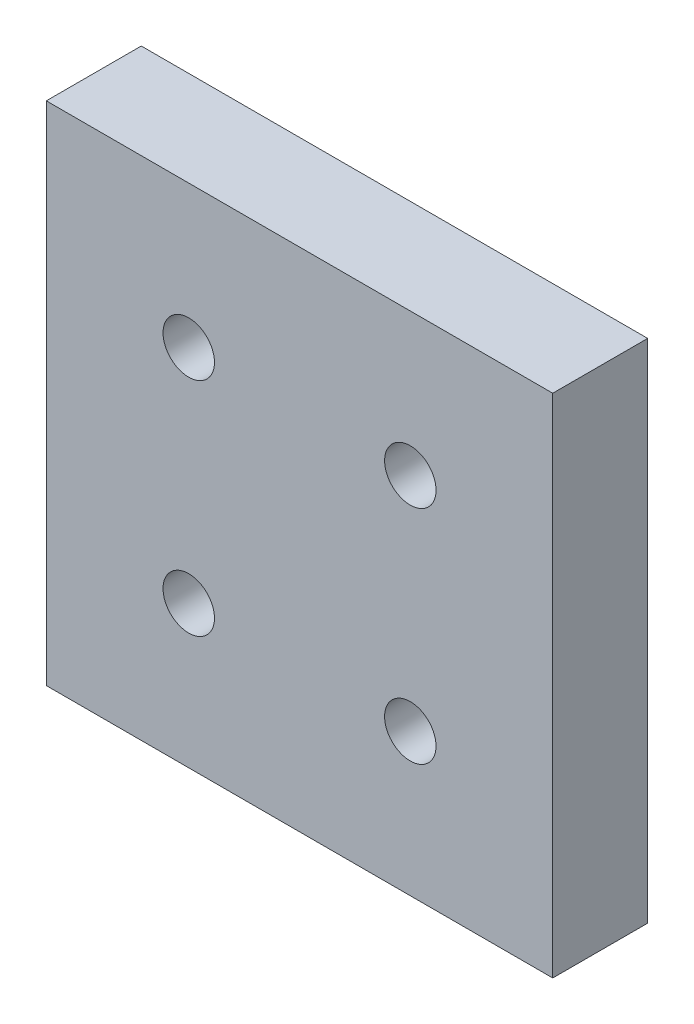
from build123d import *

# Parameters (mm, degrees)
SKETCH1_W                                        = 203.2
SKETCH1_H                                        = 203.2
BOSS_EXTRUDE1_DEPTH                              = 38.1
CBORE_FOR_1_2_SOCKET_HEAD_CAP_SCREW1_D           = 13.09624
CBORE_FOR_1_2_SOCKET_HEAD_CAP_SCREW1_CBORE_D     = 20.6375
CBORE_FOR_1_2_SOCKET_HEAD_CAP_SCREW1_CBORE_DEPTH = 19.05


with BuildPart() as part:
    # Sketch1 → Boss-Extrude1 (new body)
    with BuildSketch(Plane.XY):
        Rectangle(SKETCH1_W, SKETCH1_H)
    extrude(amount=BOSS_EXTRUDE1_DEPTH)

    # CBORE for 1/2 Socket Head Cap Screw1 (through all)
    with Locations(Plane.XY.offset(38.1)):
        with Locations((44.45, -44.45), (-44.45, -44.45), (-44.45, 44.45), (44.45, 44.45)):
            CounterBoreHole(CBORE_FOR_1_2_SOCKET_HEAD_CAP_SCREW1_D / 2, CBORE_FOR_1_2_SOCKET_HEAD_CAP_SCREW1_CBORE_D / 2, CBORE_FOR_1_2_SOCKET_HEAD_CAP_SCREW1_CBORE_DEPTH)


solid = part.part
